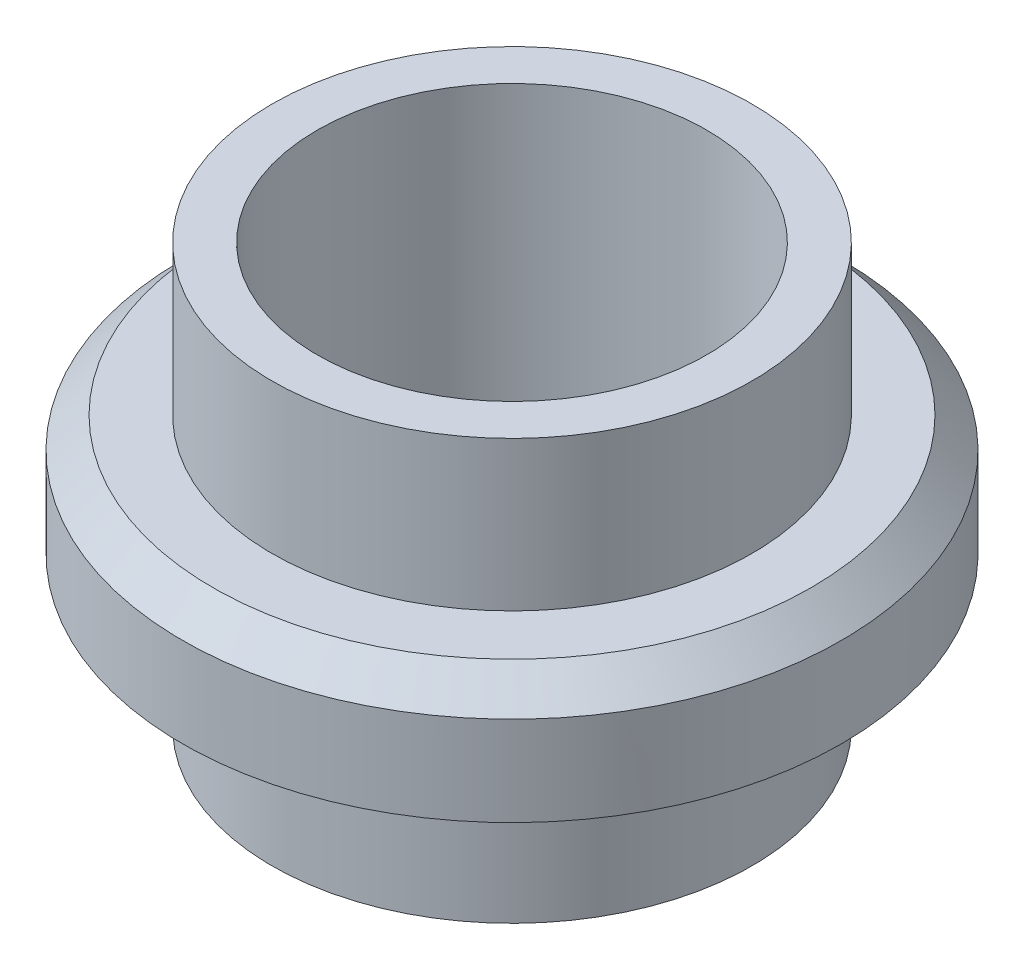
from build123d import *

# Parameters (mm, degrees)
CHAMFER1_SIZE = 3.5


with BuildPart() as part:
    # Sketch1 → Revolve2 (revolve)
    with BuildSketch(Plane.XY):
        Polygon((-8.685956571, 3.088170612), (-1.885956571, 3.088170612), (-1.885956571, -22.827972222), (3.314043429, -22.827972222), (3.314043429, 25.472027778), (-1.885956571, 25.472027778), (-1.885956571, 8.288170612), (-12.185956571, 8.288170612), (-12.185956571, 3.088170612), (-12.185956571, -5.511829388), (-8.685956571, -5.511829388), align=None)
    revolve(axis=Axis((25.714043429, 25.472027778, 0), (0, -1, 0)))

    # Chamfer1
    chamfer1_edges = [part.edges().sort_by_distance(p)[0] for p in [
        (63.614043429, 8.288170612, 0),
    ]]
    chamfer(chamfer1_edges, length=CHAMFER1_SIZE)


solid = part.part
